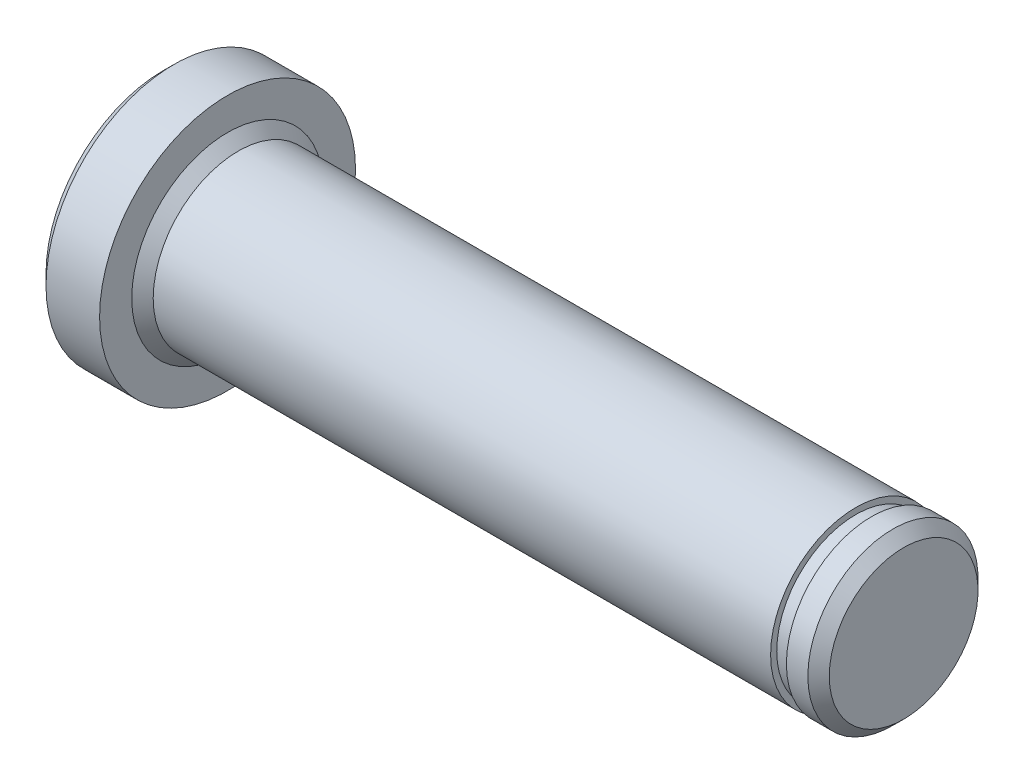
from build123d import *

# Parameters (mm, degrees)
CHAMFER1_SIZE = 0.5


with BuildPart() as part:
    # Sketch1 → Revolve1 (revolve)
    with BuildSketch(Plane.XY):
        Polygon((0, 3.96875), (0, 5.96875), (-3, 5.96875), (-3, 0), (31.5366, 0), (31.5366, 3.96875), (30.0366, 3.96875), (30.0366, 3.683), (29.3, 3.683), (29.3, 3.96875), align=None)
    revolve(axis=Axis((-20.199082849, 0, 0), (1, 0, 0)))

    # Chamfer1
    chamfer1_edges = [part.edges().sort_by_distance(p)[0] for p in [
        (0, -3.96875, 0),
        (-3, -5.96875, 0),
        (31.5366, -3.96875, 0),
    ]]
    chamfer(chamfer1_edges, length=CHAMFER1_SIZE)


solid = part.part
